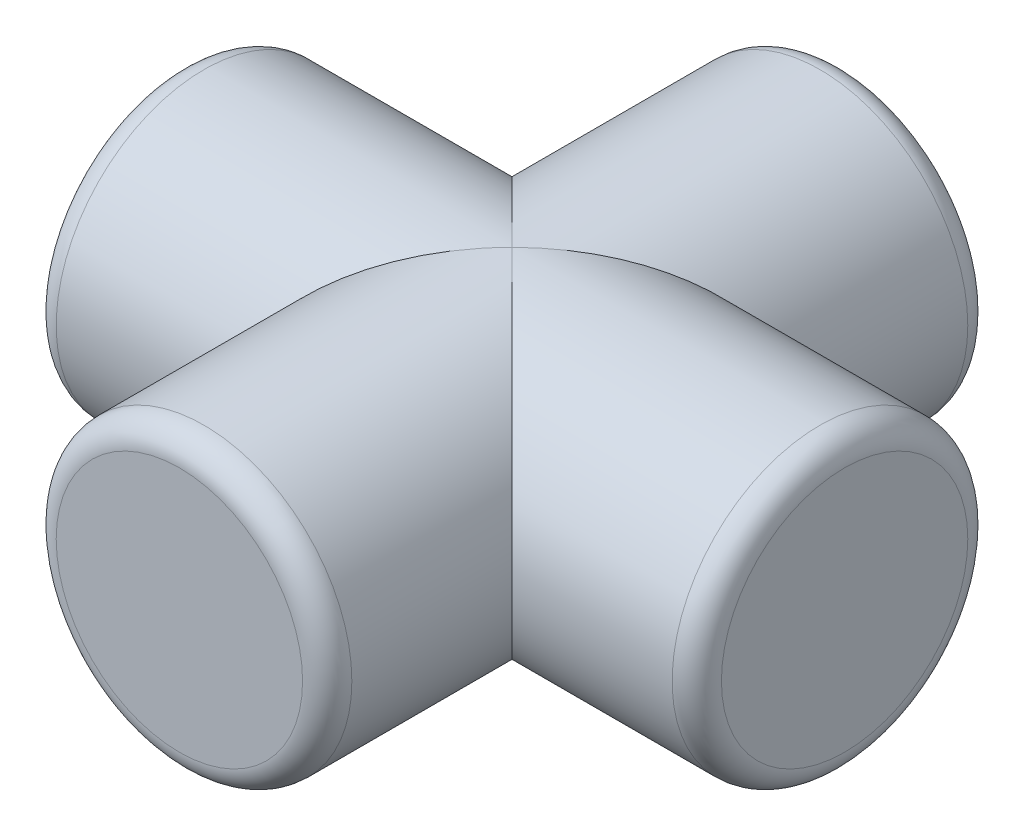
from build123d import *

# Parameters (mm, degrees)
SKETCH2_R                = 7.62
BOSS_EXTRUDE1_DEPTH      = 34.29
BOSS_EXTRUDE2_DEPTH      = 17.145
BOSS_EXTRUDE2_DEPTH_BACK = 17.145
SKETCH3_R                = 7.62
FILLET1_R                = 1.27
SCALE1_SCALE             = 2


with BuildPart() as part:
    # Sketch2 → Boss-Extrude1 (new body)
    with BuildSketch(Plane.XY):
        Circle(SKETCH2_R)
    extrude(amount=BOSS_EXTRUDE1_DEPTH)

    # Sketch3 → Boss-Extrude2 (add, two sides: drawn at the far end of the back side and taken through both)
    with BuildSketch(Plane(origin=(0, 0, 0), x_dir=(0, 0, -1), z_dir=(1, 0, 0)).offset(-BOSS_EXTRUDE2_DEPTH_BACK)):
        with Locations((-17.145, 0)):
            Circle(SKETCH3_R)
    extrude(amount=BOSS_EXTRUDE2_DEPTH + BOSS_EXTRUDE2_DEPTH_BACK)

    # Fillet1
    fillet1_edges = [part.edges().sort_by_distance(p)[0] for p in [
        (-7.62, 0, 34.29),
        (17.145, 0, 24.765),
        (-17.145, 0, 24.765),
        (-7.62, 0, 0),
    ]]
    fillet(fillet1_edges, radius=FILLET1_R)


with BuildPart() as part_1:
    # Scale1: scaled about (0, 0, 17.145)
    add(part.part.scale(SCALE1_SCALE).moved(Location((0, 0, -17.145))))


solid = part_1.part
